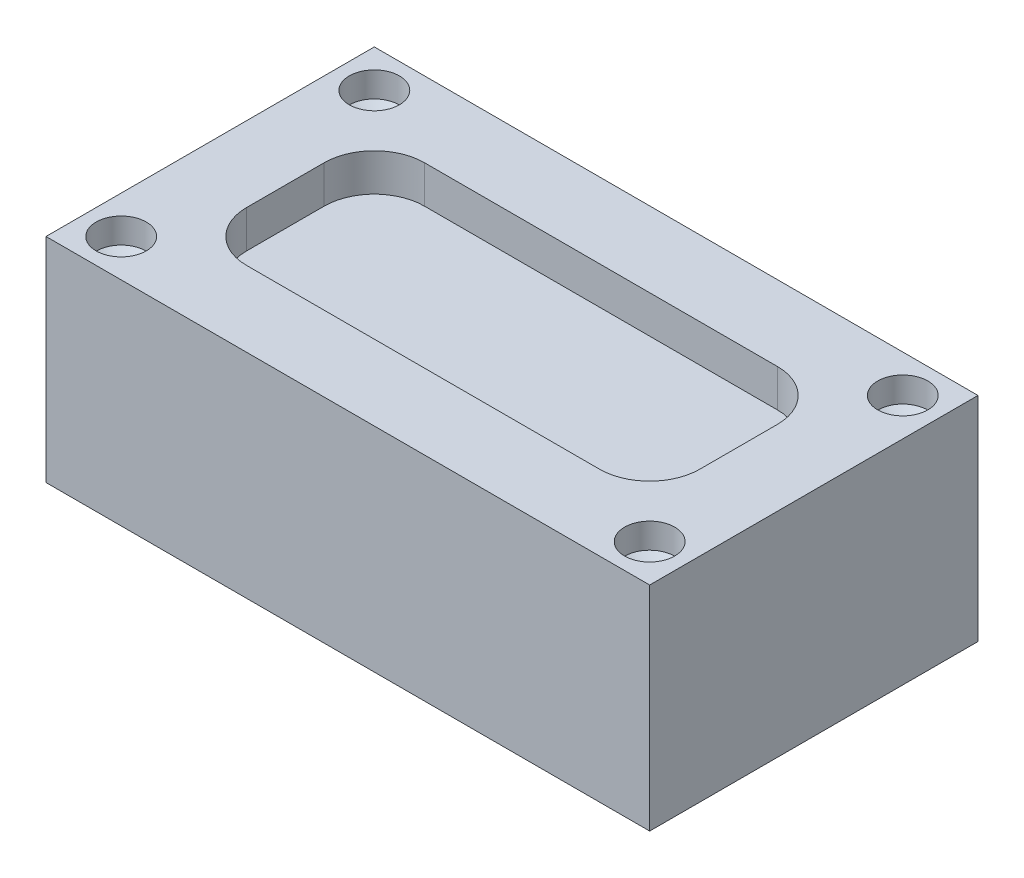
from build123d import *

# Parameters (mm, degrees)
SKETCH3_W                  = 240.765342714
SKETCH3_H                  = 130.947670476
BOSS_EXTRUDE2_DEPTH        = 85
SKETCH4_W                  = 180.765342714
SKETCH4_H                  = 70.947670476
CUT_EXTRUDE1_DEPTH         = 15
F_20_0MM_DOWEL_HOLE1_D     = 20
F_20_0MM_DOWEL_HOLE1_DEPTH = 10.05
F_20_0MM_DOWEL_HOLE1_TIP   = 6.00860619
FILLET1_R                  = 20


with BuildPart() as part:
    # Sketch3 → Boss-Extrude2 (new body)
    with BuildSketch(Plane(origin=(0, 0, 0), x_dir=(1, 0, 0), z_dir=(0, 1, 0))):
        Rectangle(SKETCH3_W, SKETCH3_H)
    extrude(amount=BOSS_EXTRUDE2_DEPTH)

    # Sketch4 → Cut-Extrude1 (cut)
    with BuildSketch(Plane(origin=(0, 85, 0), x_dir=(1, 0, 0), z_dir=(0, 1, 0))):
        Rectangle(SKETCH4_W, SKETCH4_H)
    extrude(amount=-CUT_EXTRUDE1_DEPTH, mode=Mode.SUBTRACT)

    # Ø20.0mm Dowel Hole1
    with Locations(Plane(origin=(-105.382671357, 85, -50.473835238), x_dir=(0, 0, 1), z_dir=(0, 1, 0))):
        with Locations((0, 0), (100.947670476, 0), (0, 210.765342714), (100.947670476, 210.765342714)):
            Hole(F_20_0MM_DOWEL_HOLE1_D / 2, depth=F_20_0MM_DOWEL_HOLE1_DEPTH)
            with Locations((0, 0, -(F_20_0MM_DOWEL_HOLE1_DEPTH + F_20_0MM_DOWEL_HOLE1_TIP / 2))):  # 118° drill point
                Cone(0, F_20_0MM_DOWEL_HOLE1_D / 2, F_20_0MM_DOWEL_HOLE1_TIP, mode=Mode.SUBTRACT)

    # Fillet1
    fillet1_edges = [part.edges().sort_by_distance(p)[0] for p in [
        (90.382671357, 77.5, 35.473835238),
        (-90.382671357, 77.5, 35.473835238),
        (-90.382671357, 77.5, -35.473835238),
        (90.382671357, 77.5, -35.473835238),
    ]]
    fillet(fillet1_edges, radius=FILLET1_R)


solid = part.part
